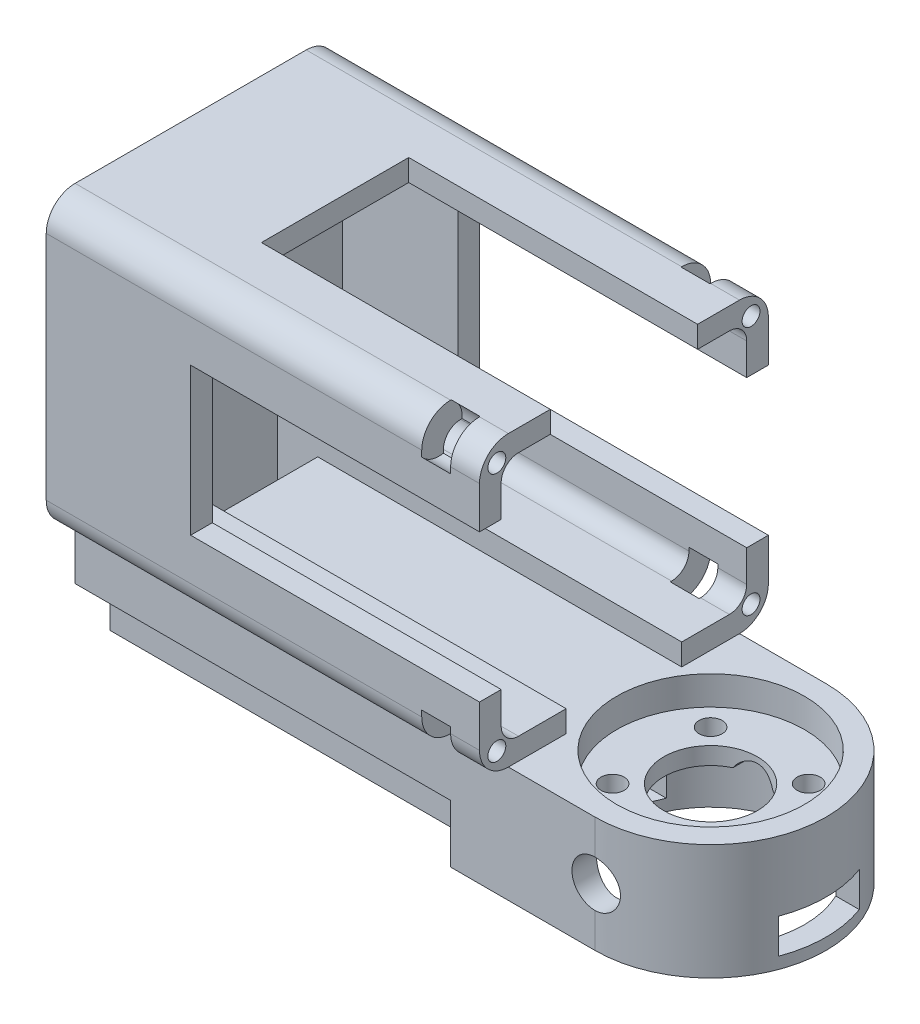
from build123d import *

# Parameters (mm, degrees)
SKETCH1_W               = 50
SKETCH1_H               = 50
BOSS_EXTRUDE1_DEPTH     = 75
FILLET1_R               = 5
SKETCH2_W               = 42.5
SKETCH2_H               = 42.5
CUT_EXTRUDE1_DEPTH      = 70
FILLET2_R               = 3
SKETCH3_W               = 25.5
SKETCH3_H               = 3.75
SKETCH3_W_2             = 3.75
SKETCH3_H_2             = 25.5
CUT_EXTRUDE2_DEPTH      = 50
SKETCH4_W               = 20
SKETCH4_H               = 3.75
CUT_EXTRUDE3_DEPTH      = 70
BOSS_EXTRUDE2_DEPTH     = 20
SKETCH6_W               = 40
SKETCH6_H               = 10
BOSS_EXTRUDE4_DEPTH     = 75
SKETCH7_W               = 7
SKETCH7_H               = 20
CUT_EXTRUDE4_DEPTH      = 8
SKETCH8_R               = 1.55
CUT_EXTRUDE5_DEPTH      = 5
SKETCH9_R               = 4
CUT_EXTRUDE6_DEPTH      = 5
MIRROR2_COPY_1_SKETCH_R = 1.55
MIRROR2_COPY_1_DEPTH    = 5
MIRROR2_COPY_2_SKETCH_R = 4
MIRROR2_COPY_2_DEPTH    = 5
SKETCH11_W              = 40
SKETCH11_H              = 10
BOSS_EXTRUDE5_DEPTH     = 10
SKETCH12_R              = 4
CUT_EXTRUDE7_DEPTH      = 46
SKETCH13_R              = 16.25
CUT_EXTRUDE8_DEPTH      = 5
SKETCH14_R              = 16.25
CUT_EXTRUDE9_DEPTH      = 12
SKETCH15_R              = 8.1
CUT_EXTRUDE10_DEPTH     = 12
SKETCH16_R              = 2
CUT_EXTRUDE11_DEPTH     = 12
SKETCH17_W              = 7
SKETCH17_H              = 20
CUT_EXTRUDE12_DEPTH     = 20
SKETCH18_W              = 65
SKETCH18_H              = 28
BOSS_EXTRUDE6_DEPTH     = 10
SKETCH19_W              = 14
SKETCH19_H              = 6
CUT_EXTRUDE13_DEPTH     = 130
SKETCH20_W              = 7
SKETCH20_H              = 20
CUT_EXTRUDE14_DEPTH     = 3


with BuildPart() as part:
    # Sketch1 → Boss-Extrude1 (new body)
    with BuildSketch(Plane(origin=(0, 0, 0), x_dir=(0, 0, -1), z_dir=(1, 0, 0))):
        Rectangle(SKETCH1_W, SKETCH1_H)
    extrude(amount=-BOSS_EXTRUDE1_DEPTH)

    # Fillet1
    fillet1_edges = [part.edges().sort_by_distance(p)[0] for p in [
        (-37.5, -25, -25),
        (-37.5, -25, 25),
        (-37.5, 25, 25),
        (-37.5, 25, -25),
    ]]
    fillet(fillet1_edges, radius=FILLET1_R)

    # Sketch2 → Cut-Extrude1 (cut)
    with BuildSketch(Plane(origin=(0, 0, 0), x_dir=(0, 0, -1), z_dir=(1, 0, 0))):
        Rectangle(SKETCH2_W, SKETCH2_H)
    extrude(amount=-CUT_EXTRUDE1_DEPTH, mode=Mode.SUBTRACT)

    # Fillet2
    fillet2_edges = [part.edges().sort_by_distance(p)[0] for p in [
        (-35, 21.25, -21.25),
        (-35, -21.25, -21.25),
        (-35, -21.25, 21.25),
        (-35, 21.25, 21.25),
    ]]
    fillet(fillet2_edges, radius=FILLET2_R)

    # Sketch3 → Cut-Extrude2 (cut)
    with BuildSketch(Plane(origin=(0, 0, 0), x_dir=(0, 0, -1), z_dir=(1, 0, 0))):
        with Locations((0, 23.125)):
            Rectangle(SKETCH3_W, SKETCH3_H)
        with Locations((-23.125, 0)):
            Rectangle(SKETCH3_W_2, SKETCH3_H_2)
        with Locations((23.125, 0)):
            Rectangle(SKETCH3_W_2, SKETCH3_H_2)
    extrude(amount=-CUT_EXTRUDE2_DEPTH, mode=Mode.SUBTRACT)

    # Sketch4 → Cut-Extrude3 (cut)
    with BuildSketch(Plane(origin=(0, 0, 0), x_dir=(0, 0, -1), z_dir=(1, 0, 0))):
        with Locations((0, -23.125)):
            Rectangle(SKETCH4_W, SKETCH4_H)
    extrude(amount=-CUT_EXTRUDE3_DEPTH, mode=Mode.SUBTRACT)



with BuildPart() as body_2:
    # Sketch5 → Boss-Extrude2 (new body)
    with BuildSketch(Plane.XZ.offset(25)):
        Polygon((15, 20), (0, 20), (0, 10), (0, -10), (0, -20), (15, -20), align=None)
        with BuildLine():
            ThreePointArc((15, 20), (35, 0), (15, -20))
            Line((15, -20), (15, 20))
        make_face()
    extrude(amount=BOSS_EXTRUDE2_DEPTH)


with BuildPart() as part_1:
    add(part.part)

    add(body_2.part)  # Boss-Extrude4 merges body 2
    # Sketch6 → Boss-Extrude4 (add)
    with BuildSketch(Plane.ZY):
        with Locations((0, -30)):
            Rectangle(SKETCH6_W, SKETCH6_H)
    extrude(amount=BOSS_EXTRUDE4_DEPTH)

    # Sketch7 → Cut-Extrude4 (cut)
    with BuildSketch(Plane(origin=(0, -25, 0), x_dir=(1, 0, 0), z_dir=(0, 1, 0))):
        with Locations((-66.5, 0)):
            Rectangle(SKETCH7_W, SKETCH7_H)
    extrude(amount=-CUT_EXTRUDE4_DEPTH, mode=Mode.SUBTRACT)

    # Sketch8 → Cut-Extrude5 (cut)
    with BuildSketch(Plane(origin=(0, 0, 0), x_dir=(0, 0, -1), z_dir=(1, 0, 0))):
        with Locations((-22, 21.6)):
            Circle(SKETCH8_R)
    cut_extrude5 = extrude(amount=-CUT_EXTRUDE5_DEPTH, mode=Mode.SUBTRACT)

    # Sketch9 → Cut-Extrude6 (cut)
    with BuildSketch(Plane(origin=(-5, 0, 0), x_dir=(0, 0, -1), z_dir=(1, 0, 0))):
        with Locations((-22, 21.6)):
            Circle(SKETCH9_R)
    cut_extrude6 = extrude(amount=-CUT_EXTRUDE6_DEPTH, mode=Mode.SUBTRACT)

    # Mirror1: Cut-Extrude5, Cut-Extrude6 across plane
    add(cut_extrude5.mirror(Plane.ZX), mode=Mode.SUBTRACT)
    add(cut_extrude6.mirror(Plane.ZX), mode=Mode.SUBTRACT)

    # Mirror2: Cut-Extrude5, Cut-Extrude6 across plane
    add(cut_extrude5.mirror(Plane.XY), mode=Mode.SUBTRACT)
    add(cut_extrude6.mirror(Plane.XY), mode=Mode.SUBTRACT)

    # Mirror2 copy 1 sketch → Mirror2 copy 1 (cut)
    with BuildSketch(Plane(origin=(0, 0, 0), x_dir=(0, 0, 1), z_dir=(1, 0, 0))):
        with Locations((-22, 21.6)):
            Circle(MIRROR2_COPY_1_SKETCH_R)
    extrude(amount=-MIRROR2_COPY_1_DEPTH, mode=Mode.SUBTRACT)

    # Mirror2 copy 2 sketch → Mirror2 copy 2 (cut)
    with BuildSketch(Plane(origin=(-5, 0, 0), x_dir=(0, 0, 1), z_dir=(1, 0, 0))):
        with Locations((-22, 21.6)):
            Circle(MIRROR2_COPY_2_SKETCH_R)
    extrude(amount=-MIRROR2_COPY_2_DEPTH, mode=Mode.SUBTRACT)

    # Sketch11 → Boss-Extrude5 (add)
    with BuildSketch(Plane.ZY):
        with Locations((0, -40)):
            Rectangle(SKETCH11_W, SKETCH11_H)
    extrude(amount=BOSS_EXTRUDE5_DEPTH)

    # Sketch12 → Cut-Extrude7 (cut, through all)
    with BuildSketch(Plane.XY.offset(20)):
        with Locations((15, -35)):
            Circle(SKETCH12_R)
    extrude(amount=-CUT_EXTRUDE7_DEPTH, mode=Mode.SUBTRACT)

    # Sketch13 → Cut-Extrude8 (cut)
    with BuildSketch(Plane(origin=(0, -25, 0), x_dir=(1, 0, 0), z_dir=(0, 1, 0))):
        with Locations((15, 0)):
            Circle(SKETCH13_R)
    extrude(amount=-CUT_EXTRUDE8_DEPTH, mode=Mode.SUBTRACT)

    # Sketch14 → Cut-Extrude9 (cut)
    with BuildSketch(Plane.XZ.offset(45)):
        with Locations((15, 0)):
            Circle(SKETCH14_R)
    extrude(amount=-CUT_EXTRUDE9_DEPTH, mode=Mode.SUBTRACT)

    # Sketch15 → Cut-Extrude10 (cut)
    with BuildSketch(Plane(origin=(0, -30, 0), x_dir=(1, 0, 0), z_dir=(0, 1, 0))):
        with Locations((15, 0)):
            Circle(SKETCH15_R)
    extrude(amount=-CUT_EXTRUDE10_DEPTH, mode=Mode.SUBTRACT)

    # Sketch16 → Cut-Extrude11 (cut)
    with BuildSketch(Plane.XZ.offset(33)):
        with Locations((6.514718626, 8.485281374)):
            Circle(SKETCH16_R)
        with Locations((23.485281374, 8.485281374)):
            Circle(SKETCH16_R)
        with Locations((23.485281374, -8.485281374)):
            Circle(SKETCH16_R)
        with Locations((6.514718626, -8.485281374)):
            Circle(SKETCH16_R)
    extrude(amount=-CUT_EXTRUDE11_DEPTH, mode=Mode.SUBTRACT)

    # Sketch17 → Cut-Extrude12 (cut)
    with BuildSketch(Plane(origin=(0, -33, 0), x_dir=(1, 0, 0), z_dir=(0, 1, 0))):
        with Locations((-66.5, 0)):
            Rectangle(SKETCH17_W, SKETCH17_H)
    extrude(amount=-CUT_EXTRUDE12_DEPTH, mode=Mode.SUBTRACT)

    # Sketch18 → Boss-Extrude6 (add)
    with BuildSketch(Plane.XZ.offset(35)):
        with Locations((-42.5, 0)):
            Rectangle(SKETCH18_W, SKETCH18_H)
    extrude(amount=BOSS_EXTRUDE6_DEPTH)

    # Sketch19 → Cut-Extrude13 (cut)
    with BuildSketch(Plane.ZY.offset(75)):
        with Locations((0, -40)):
            Rectangle(SKETCH19_W, SKETCH19_H)
    extrude(amount=-CUT_EXTRUDE13_DEPTH, mode=Mode.SUBTRACT)

    # Sketch20 → Cut-Extrude14 (cut)
    with BuildSketch(Plane(origin=(0, -35, 0), x_dir=(1, 0, 0), z_dir=(0, 1, 0))):
        with Locations((-66.5, 0)):
            Rectangle(SKETCH20_W, SKETCH20_H)
    extrude(amount=-CUT_EXTRUDE14_DEPTH, mode=Mode.SUBTRACT)


solid = part_1.part
